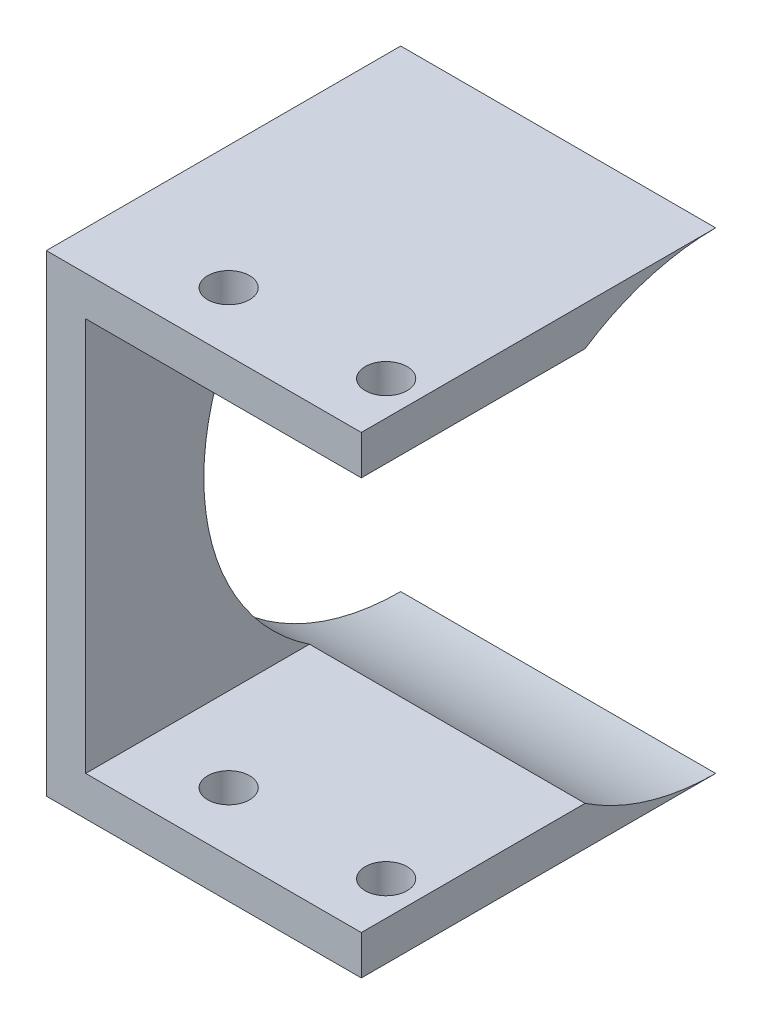
from build123d import *

# Parameters (mm, degrees)
SKETCH2_W               = 50.8
SKETCH2_H               = 76.2
BOSS_EXTRUDE2_DEPTH     = 57.15
SKETCH3_R               = 38.1
CUT_EXTRUDE1_DEPTH      = 108.95
SHELL1_T                = -6.35
F_1_4_CLEARANCE_HOLE1_D = 6.7564


with BuildPart() as part:
    # Sketch2 → Boss-Extrude2 (new body)
    with BuildSketch(Plane.XY):
        with Locations((25.4, 38.1)):
            Rectangle(SKETCH2_W, SKETCH2_H)
    extrude(amount=BOSS_EXTRUDE2_DEPTH)

    # Sketch3 → Cut-Extrude1 (cut, through all)
    with BuildSketch(Plane(origin=(50.8, 0, 0), x_dir=(0, 0, -1), z_dir=(1, 0, 0))):
        with Locations((0, 38.1)):
            Circle(SKETCH3_R)
    extrude(amount=-CUT_EXTRUDE1_DEPTH, mode=Mode.SUBTRACT)

    # Shell1
    shell1_openings = [part.faces().sort_by_distance(p)[0] for p in [
        (25.4, 38.1, 57.15),
        (25.4, 38.1, 38.1),
        (50.8, 38.1, 42.20881959),
    ]]
    offset(amount=SHELL1_T, openings=shell1_openings, kind=Kind.INTERSECTION)

    # 1/4 Clearance Hole1 (through all)
    with Locations(Plane(origin=(0, 76.2, 0), x_dir=(1, 0, 0), z_dir=(0, 1, 0))):
        with Locations((45.28185, -47.625), (19.88185, -47.625)):
            Hole(F_1_4_CLEARANCE_HOLE1_D / 2)


solid = part.part
